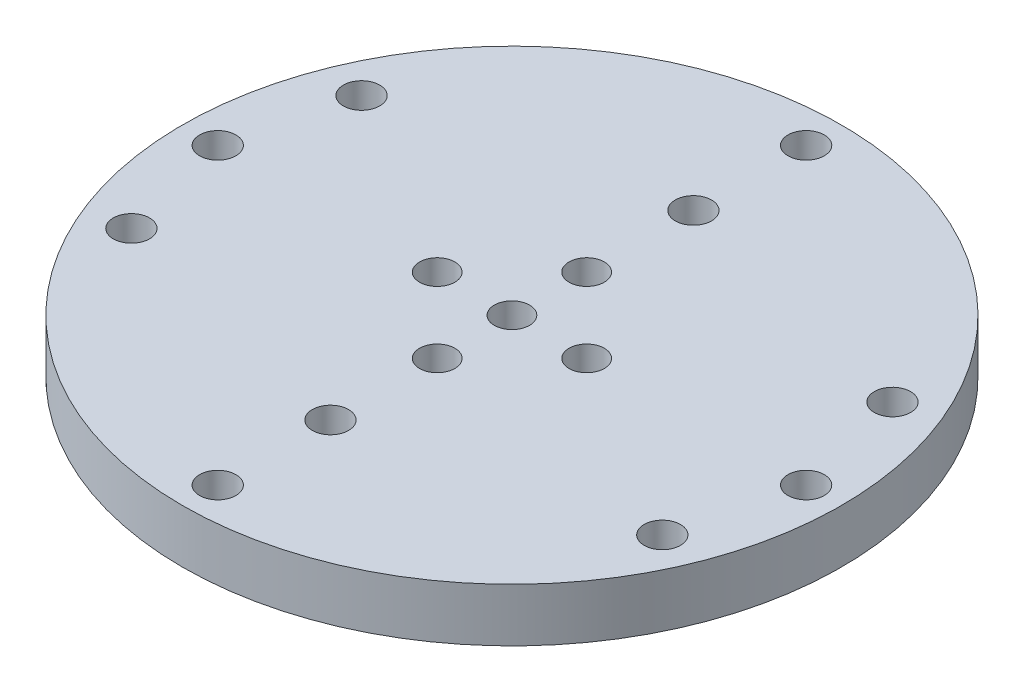
from build123d import *

# Parameters (mm, degrees)
SKETCH1_R                                       = 22
BOSS_EXTRUDE1_DEPTH                             = 4.3
SKETCH2_R                                       = 12
BOSS_EXTRUDE2_DEPTH                             = 8.25
SKETCH3_R                                       = 1.65
CUT_EXTRUDE2_DEPTH                              = 14.5
SKETCH4_R                                       = 30.87
SKETCH4_R_2                                     = 1.65
BOSS_EXTRUDE4_DEPTH                             = 5
SKETCH6_R                                       = 1.65
CUT_EXTRUDE4_DEPTH                              = 10
CSK_FOR_M3_FLAT_HEAD_MACHINE_SCREW2_D           = 3.4
CSK_FOR_M3_FLAT_HEAD_MACHINE_SCREW2_CSINK_D     = 6.3
CSK_FOR_M3_FLAT_HEAD_MACHINE_SCREW2_CSINK_ANGLE = 90
SKETCH5_R                                       = 1.65
CUT_EXTRUDE3_DEPTH                              = 25
CSK_FOR_M3_FLAT_HEAD_MACHINE_SCREW3_D           = 3.4
CSK_FOR_M3_FLAT_HEAD_MACHINE_SCREW3_CSINK_D     = 6.3
CSK_FOR_M3_FLAT_HEAD_MACHINE_SCREW3_CSINK_ANGLE = 90


with BuildPart() as part:
    # Sketch1 → Boss-Extrude1 (new body)
    with BuildSketch(Plane(origin=(0, 0, 0), x_dir=(1, 0, 0), z_dir=(0, 1, 0))):
        Circle(SKETCH1_R)
    extrude(amount=BOSS_EXTRUDE1_DEPTH)

    # Sketch2 → Boss-Extrude2 (add)
    with BuildSketch(Plane.XZ):
        Circle(SKETCH2_R)
    extrude(amount=BOSS_EXTRUDE2_DEPTH)

    # Sketch3 → Cut-Extrude2 (cut)
    with BuildSketch(Plane(origin=(0, 4.3, 0), x_dir=(1, 0, 0), z_dir=(0, 1, 0))):
        Circle(SKETCH3_R)
        with Locations((0, 7)):
            Circle(SKETCH3_R)
        with Locations((7, 0)):
            Circle(SKETCH3_R)
        with Locations((0, -7)):
            Circle(SKETCH3_R)
        with Locations((-7, 0)):
            Circle(SKETCH3_R)
    extrude(amount=-CUT_EXTRUDE2_DEPTH, mode=Mode.SUBTRACT)

    # Sketch4 → Boss-Extrude4 (add)
    with BuildSketch(Plane(origin=(0, 4.3, 0), x_dir=(1, 0, 0), z_dir=(0, 1, 0))):
        Circle(SKETCH4_R)
        Circle(SKETCH4_R_2, mode=Mode.SUBTRACT)
        with Locations((0, 7)):
            Circle(SKETCH4_R_2, mode=Mode.SUBTRACT)
        with Locations((7, 0)):
            Circle(SKETCH4_R_2, mode=Mode.SUBTRACT)
        with Locations((0, -7)):
            Circle(SKETCH4_R_2, mode=Mode.SUBTRACT)
        with Locations((-7, 0)):
            Circle(SKETCH4_R_2, mode=Mode.SUBTRACT)
        with Locations((0, -17)):
            Circle(SKETCH4_R_2, mode=Mode.SUBTRACT)
        with Locations((0, 17)):
            Circle(SKETCH4_R_2, mode=Mode.SUBTRACT)
    extrude(amount=BOSS_EXTRUDE4_DEPTH)

    # Sketch6 → Cut-Extrude4 (cut)
    with BuildSketch(Plane(origin=(0, 9.3, 0), x_dir=(1, 0, 0), z_dir=(0, 1, 0))):
        with Locations((0, 27.5567407)):
            Circle(SKETCH6_R)
        with Locations((0, -27.5567407)):
            Circle(SKETCH6_R)
        with Locations((-24.864837492, -10.77837035)):
            Circle(SKETCH6_R)
        with Locations((-24.864837492, 10.77837035)):
            Circle(SKETCH6_R)
        with Locations((-27.5567407, 0)):
            Circle(SKETCH6_R)
        with Locations((27.5567407, 0)):
            Circle(SKETCH6_R)
        with Locations((24.864837492, -10.77837035)):
            Circle(SKETCH6_R)
        with Locations((24.864837492, 10.77837035)):
            Circle(SKETCH6_R)
    extrude(amount=-CUT_EXTRUDE4_DEPTH, mode=Mode.SUBTRACT)

    # CSK for M3 Flat Head Machine Screw2 (through all)
    with Locations(Plane(origin=(0, 4.3, 0), x_dir=(-1, 0, 0), z_dir=(0, -1, 0))):
        with Locations((0, -27.5567407), (-24.864837492, -10.77837035), (-27.5567407, 0), (-24.864837492, 10.77837035), (0, 27.5567407), (24.864837492, 10.77837035), (27.5567407, 0), (24.864837492, -10.77837035)):
            CounterSinkHole(CSK_FOR_M3_FLAT_HEAD_MACHINE_SCREW2_D / 2, CSK_FOR_M3_FLAT_HEAD_MACHINE_SCREW2_CSINK_D / 2, counter_sink_angle=CSK_FOR_M3_FLAT_HEAD_MACHINE_SCREW2_CSINK_ANGLE)

    # Sketch5 → Cut-Extrude3 (cut)
    with BuildSketch(Plane(origin=(0, 9.3, 0), x_dir=(1, 0, 0), z_dir=(0, 1, 0))):
        with Locations((0, -7)):
            Circle(SKETCH5_R)
        with Locations((0, 7)):
            Circle(SKETCH5_R)
        with Locations((0, -17)):
            Circle(SKETCH5_R)
        with Locations((0, 17)):
            Circle(SKETCH5_R)
    extrude(amount=-CUT_EXTRUDE3_DEPTH, mode=Mode.SUBTRACT)

    # CSK for M3 Flat Head Machine Screw3 (through all)
    with Locations(Plane(origin=(0, 0, 0), x_dir=(-1, 0, 0), z_dir=(0, -1, 0))):
        with Locations((0, -17), (0, 17)):
            CounterSinkHole(CSK_FOR_M3_FLAT_HEAD_MACHINE_SCREW3_D / 2, CSK_FOR_M3_FLAT_HEAD_MACHINE_SCREW3_CSINK_D / 2, counter_sink_angle=CSK_FOR_M3_FLAT_HEAD_MACHINE_SCREW3_CSINK_ANGLE)


solid = part.part
